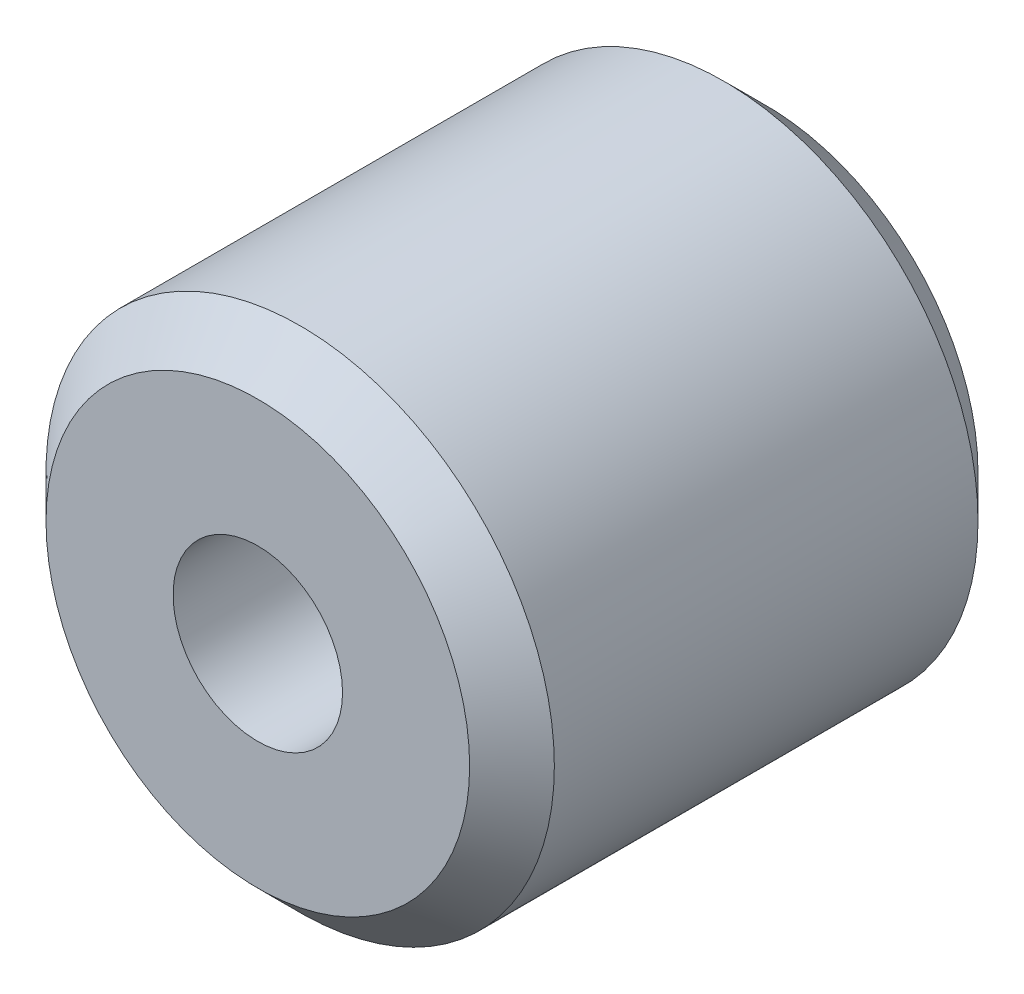
from build123d import *

# Parameters (mm, degrees)
SKETCH1_R           = 6
BOSS_EXTRUDE1_DEPTH = 12
SKETCH2_R           = 2
CUT_EXTRUDE1_DEPTH  = 13
CHAMFER1_SIZE       = 1


with BuildPart() as part:
    # Sketch1 → Boss-Extrude1 (new body)
    with BuildSketch(Plane.XY):
        Circle(SKETCH1_R)
    extrude(amount=BOSS_EXTRUDE1_DEPTH)

    # Sketch2 → Cut-Extrude1 (cut, through all)
    with BuildSketch(Plane.XY):
        Circle(SKETCH2_R)
    extrude(amount=CUT_EXTRUDE1_DEPTH, mode=Mode.SUBTRACT)

    # Chamfer1
    chamfer1_edges = [part.edges().sort_by_distance(p)[0] for p in [
        (-6, 0, 0),
        (-6, 0, 12),
    ]]
    chamfer(chamfer1_edges, length=CHAMFER1_SIZE)


solid = part.part
